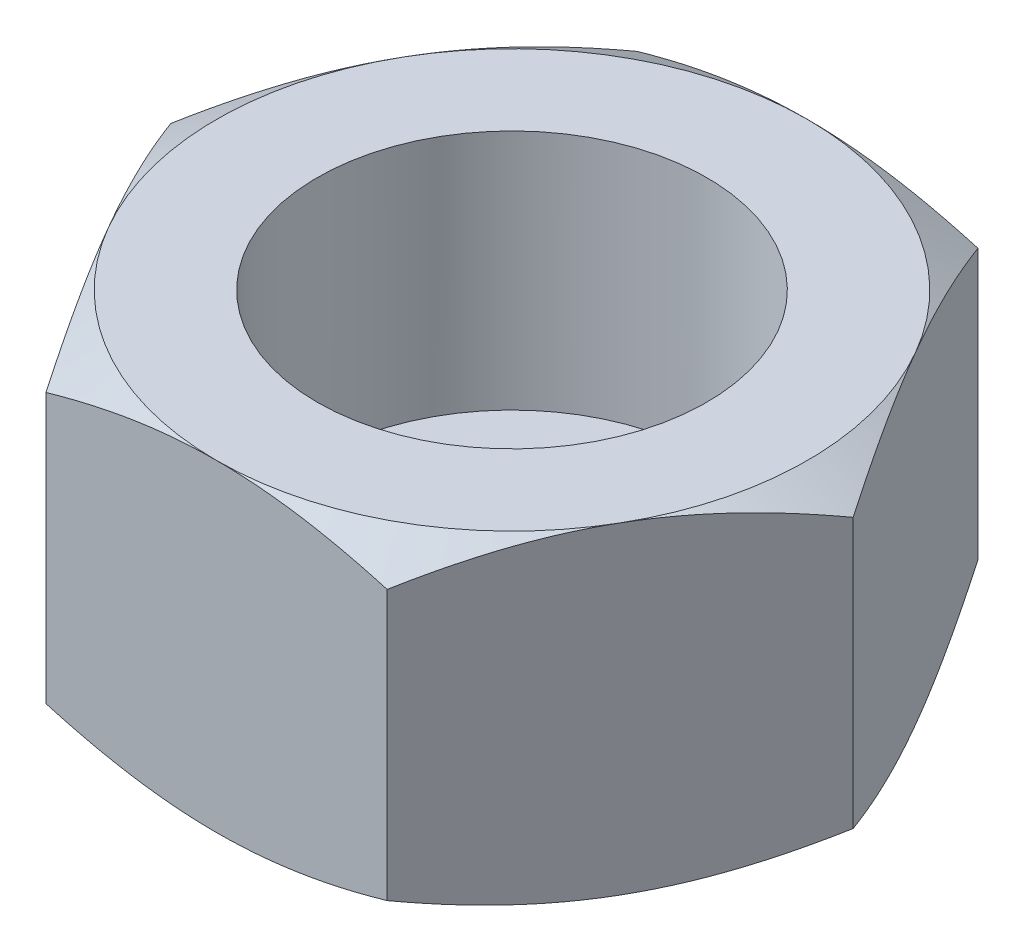
from build123d import *

# Parameters (mm, degrees)
AUFSATZ_LINEAR_AUSTRAGEN1_DEPTH = 12
SKIZZE2_R                       = 5
SCHNITT_LINEAR_AUSTRAGEN1_DEPTH = 3
M16X1_5_GEWINDEBOHRUNG1_D       = 14.5
M16X1_5_GEWINDEBOHRUNG1_DEPTH   = 9


with BuildPart() as part:
    # Skizze1 → Aufsatz-Linear austragen1 (new body)
    with BuildSketch(Plane(origin=(0, 0, 0), x_dir=(1, 0, 0), z_dir=(0, 1, 0))):
        Polygon((12.701705922, 0), (6.350852961, 11), (-6.350852961, 11), (-12.701705922, 0), (-6.350852961, -11), (6.350852961, -11), align=None)
    extrude(amount=AUFSATZ_LINEAR_AUSTRAGEN1_DEPTH)

    # Skizze2 → Schnitt-Linear austragen1 (cut)
    with BuildSketch(Plane.XZ):
        Circle(SKIZZE2_R)
    extrude(amount=-SCHNITT_LINEAR_AUSTRAGEN1_DEPTH, mode=Mode.SUBTRACT)

    # M16x1.5 Gewindebohrung1
    with Locations(Plane(origin=(0, 12, 0), x_dir=(1, 0, 0), z_dir=(0, 1, 0))):
        with Locations((0, 0)):
            Hole(M16X1_5_GEWINDEBOHRUNG1_D / 2, depth=M16X1_5_GEWINDEBOHRUNG1_DEPTH)

    # Skizze5 → Schnitt-Rotation1 (revolve, cut)
    with BuildSketch(Plane.XY):
        Polygon((-12.701705922, 12), (-11, 12), (-12.701705922, 11.017519628), align=None)
        Polygon((-12.701705922, 0), (-11, 0), (-12.701705922, 0.982480372), align=None)
    revolve(axis=Axis((0, 0, 0), (0, 1, 0)), mode=Mode.SUBTRACT)


solid = part.part
